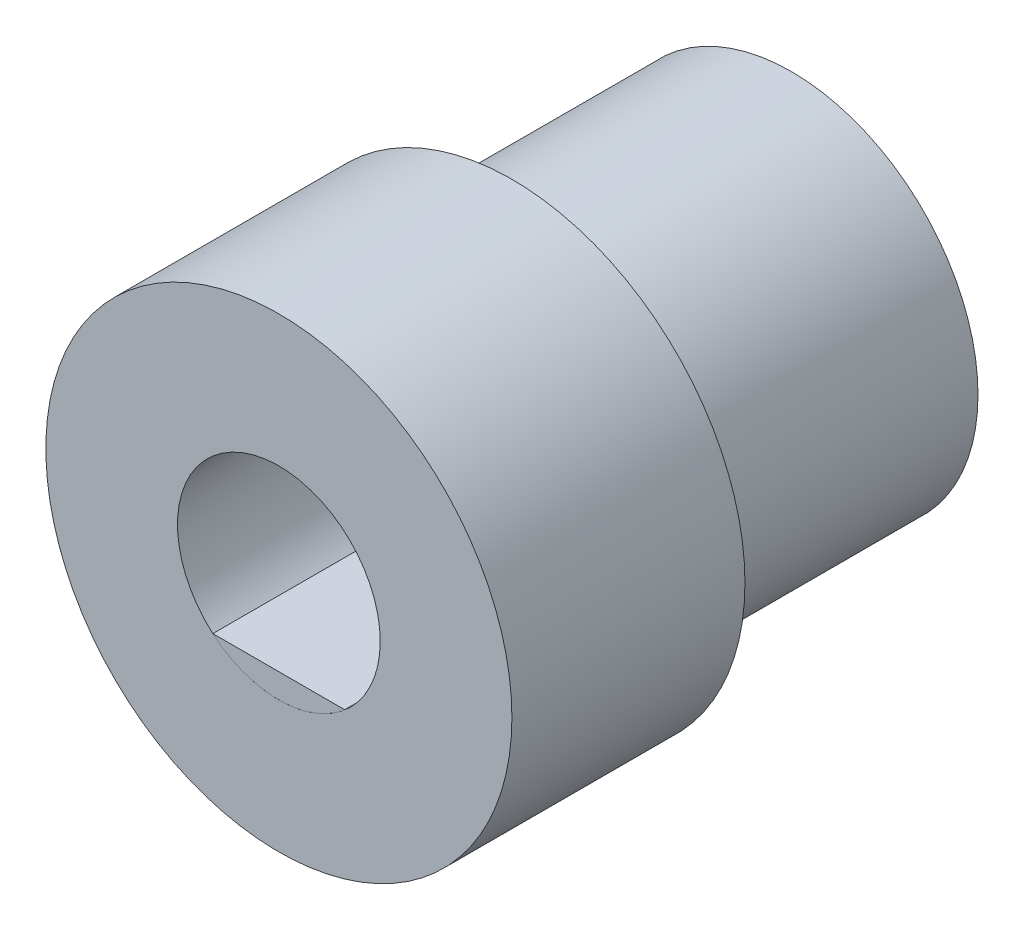
from build123d import *

# Parameters (mm, degrees)
ESQUISSE1_R             = 10
BOSS_EXTRU_1_DEPTH      = 10
ESQUISSE2_R             = 8
BOSS_EXTRU_2_DEPTH      = 12
ESQUISSE3_R             = 4.35
ENL_V_MAT_EXTRU_1_DEPTH = 10
ESQUISSE4_R             = 2.35
ENL_V_MAT_EXTRU_2_DEPTH = 12
BOSS_EXTRU_3_REACH      = 28.153
BOSS_EXTRU_4_DEPTH      = 12


with BuildPart() as part:
    # Esquisse1 → Boss.-Extru.1 (new body)
    with BuildSketch(Plane.XY):
        Circle(ESQUISSE1_R)
    extrude(amount=BOSS_EXTRU_1_DEPTH)

    # Esquisse3 → Enlèv. mat.-Extru.1 (cut)
    with BuildSketch(Plane.XY.offset(10)):
        Circle(ESQUISSE3_R)
    extrude(amount=-ENL_V_MAT_EXTRU_1_DEPTH, mode=Mode.SUBTRACT)



with BuildPart() as body_2:
    # Esquisse2 → Boss.-Extru.2 (new body)
    with BuildSketch(Plane(origin=(0, 0, 0), x_dir=(-1, 0, 0), z_dir=(0, 0, -1))):
        Circle(ESQUISSE2_R)
    extrude(amount=BOSS_EXTRU_2_DEPTH)

    # Esquisse4 → Enlèv. mat.-Extru.2 (cut)
    with BuildSketch(Plane(origin=(0, 0, -12), x_dir=(-1, 0, 0), z_dir=(0, 0, -1))):
        Circle(ESQUISSE4_R)
    extrude(amount=-ENL_V_MAT_EXTRU_2_DEPTH, mode=Mode.SUBTRACT)


with BuildPart() as body_3:

    # Esquisse5 → Boss.-Extru.3 (new, up to next)
    with BuildSketch(Plane.XY.offset(10), mode=Mode.PRIVATE) as boss_extru_3_sk1:
        with BuildLine():
            Line((-2.834166544, -3.3), (2.834166544, -3.3))
            ThreePointArc((2.834166544, -3.3), (0, -4.35), (-2.834166544, -3.3))
        make_face()
    boss_extru_3_tool1 = extrude(boss_extru_3_sk1.sketch, amount=-BOSS_EXTRU_3_REACH, mode=Mode.PRIVATE) - body_2.part
    add(boss_extru_3_tool1.solids().sort_by_distance((0, -3.724673, 10))[0])


with BuildPart() as part_1:
    add(part.part)

    add(body_2.part)  # Boss.-Extru.4 merges body 2
    # Esquisse6 → Boss.-Extru.4 (add)
    with BuildSketch(Plane(origin=(0, 0, -12), x_dir=(-1, 0, 0), z_dir=(0, 0, -1))):
        with BuildLine():
            Line((-2.020519735, -1.2), (2.020519735, -1.2))
            ThreePointArc((2.020519735, -1.2), (0, -2.35), (-2.020519735, -1.2))
        make_face()
    extrude(amount=-BOSS_EXTRU_4_DEPTH)


solid = Compound([body_3.part, part_1.part])
